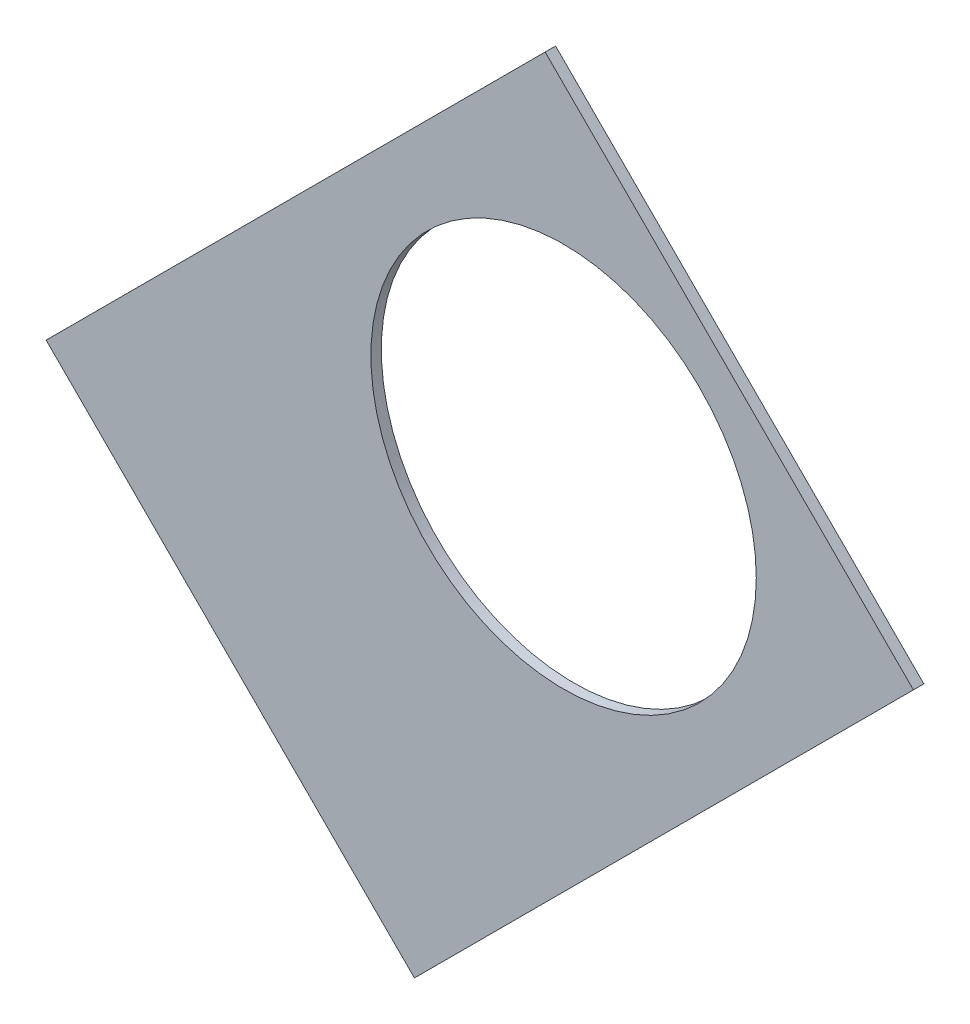
from build123d import *

# Parameters (mm, degrees)
BOSS_EXTRUDE1_DEPTH = 0.254
SKETCH2_R           = 4.699
CUT_EXTRUDE1_DEPTH  = 1.254
SKETCH3_W           = 2.54
SKETCH3_H           = 0.635
CUT_EXTRUDE2_DEPTH  = 1.254
SKETCH5_OUTSIDE_W   = 121.447
SKETCH5_OUTSIDE_H   = 109.618
CUT_EXTRUDE5_DEPTH  = 1.254


with BuildPart() as part:
    # Sketch1 → Boss-Extrude1 (new body)
    with BuildSketch(Plane.XY):
        with BuildLine():
            Line((67.21146711, 76.191723231), (8.696654013, 17.676910134))
            Line((8.696654013, 17.676910134), (7.228954972, 14.133571205))
            ThreePointArc((7.228954972, 14.133571205), (14.666587579, 6.075099489), (15.105587123, -4.88230096))
            Line((15.105587123, -4.88230096), (18.648926052, -6.35))
            Line((18.648926052, -6.35), (101.401368334, -6.35))
            ThreePointArc((101.401368334, -6.35), (93.866160503, 38.880636728), (67.21146711, 76.191723231))
        make_face()
        with BuildLine():
            Line((88.672924278, 6.35), (27.86051193, 6.35))
            ThreePointArc((27.86051193, 6.35), (26.399857642, 10.93517908), (24.190484974, 15.210228852))
            Line((24.190484974, 15.210228852), (67.191354125, 58.211098004))
            ThreePointArc((67.191354125, 58.211098004), (82.13289044, 34.020557137), (88.672924278, 6.35))
        make_face(mode=Mode.SUBTRACT)
    extrude(amount=BOSS_EXTRUDE1_DEPTH)

    # Sketch2 → Cut-Extrude1 (cut, through all)
    with BuildSketch(Plane.XY.offset(0.254)):
        with Locations((22.225, 0)):
            Circle(SKETCH2_R)
        with Locations((36.195, 0)):
            Circle(SKETCH2_R)
        with Locations((61.722, 0)):
            Circle(SKETCH2_R)
        with Locations((75.692, 0)):
            Circle(SKETCH2_R)
        with Locations((95.25, 0)):
            Circle(SKETCH2_R)
        with Locations((15.715448212, 15.715448212)):
            Circle(SKETCH2_R)
        with Locations((25.593729945, 25.593729945)):
            Circle(SKETCH2_R)
        with Locations((43.644044748, 43.644044748)):
            Circle(SKETCH2_R)
        with Locations((53.522326482, 53.522326482)):
            Circle(SKETCH2_R)
        with Locations((92.004434954, 24.652514046)):
            Circle(SKETCH2_R)
        with Locations((82.48891971, 47.625)):
            Circle(SKETCH2_R)
        with Locations((67.351920908, 67.351920908)):
            Circle(SKETCH2_R)
    extrude(amount=-CUT_EXTRUDE1_DEPTH, mode=Mode.SUBTRACT)

    # Sketch3 → Cut-Extrude2 (cut, through all)
    with BuildSketch(Plane.XY.offset(0.254)):
        Polygon((15.266435406, 24.246691527), (17.06248663, 26.042742751), (17.511499436, 25.593729945), (15.715448212, 23.797678721), align=None)
        Polygon((44.991083167, 53.971339288), (43.195031942, 52.175288063), (43.644044748, 51.726275257), (45.440095973, 53.522326482), align=None)
        with Locations((29.21, -6.0325)):
            Rectangle(SKETCH3_W, SKETCH3_H)
        with Locations((68.707, -6.0325)):
            Rectangle(SKETCH3_W, SKETCH3_H)
        Polygon((29.230733674, 38.210989795), (31.026784898, 40.007041019), (31.475797704, 39.558028213), (29.67974648, 37.761976989), align=None)
        Polygon((56.845021246, 65.825277367), (55.048970022, 64.029226143), (55.497982828, 63.580213337), (57.294034052, 65.376264561), align=None)
        with Locations((48.9585, -6.0325)):
            Rectangle(SKETCH3_W, SKETCH3_H)
        with Locations((85.471, -6.0325)):
            Rectangle(SKETCH3_W, SKETCH3_H)
        Polygon((99.935462164, 14.437711971), (100.266998693, 11.919442024), (101.526133667, 12.085210288), (101.194597138, 14.603480236), align=None)
        Polygon((93.765504959, 37.464305742), (94.938831965, 37.950313702), (93.966816047, 40.296967714), (92.793489041, 39.810959755), align=None)
        Polygon((79.327792988, 62.471156422), (80.874047017, 60.456038938), (81.88160576, 61.229165953), (80.33535173, 63.244283437), align=None)
        Polygon((13.593916116, 7.005422516), (14.565932035, 4.658768503), (15.739259041, 5.144776462), (14.767243123, 7.491430475), align=None)
    extrude(amount=-CUT_EXTRUDE2_DEPTH, mode=Mode.SUBTRACT)

    # Sketch5 outside → Cut-Extrude5 (cut, through all)
    with BuildSketch(Plane.XY.offset(0.254)):
        with Locations((54.4145, 34.921)):
            Rectangle(SKETCH5_OUTSIDE_W, SKETCH5_OUTSIDE_H)
        Polygon((30.128759286, 40.905066631), (42.29700633, 53.073313676), (53.073313676, 42.29700633), (40.905066631, 30.128759286), align=None, mode=Mode.SUBTRACT)
    extrude(amount=-CUT_EXTRUDE5_DEPTH, mode=Mode.SUBTRACT)


solid = part.part
